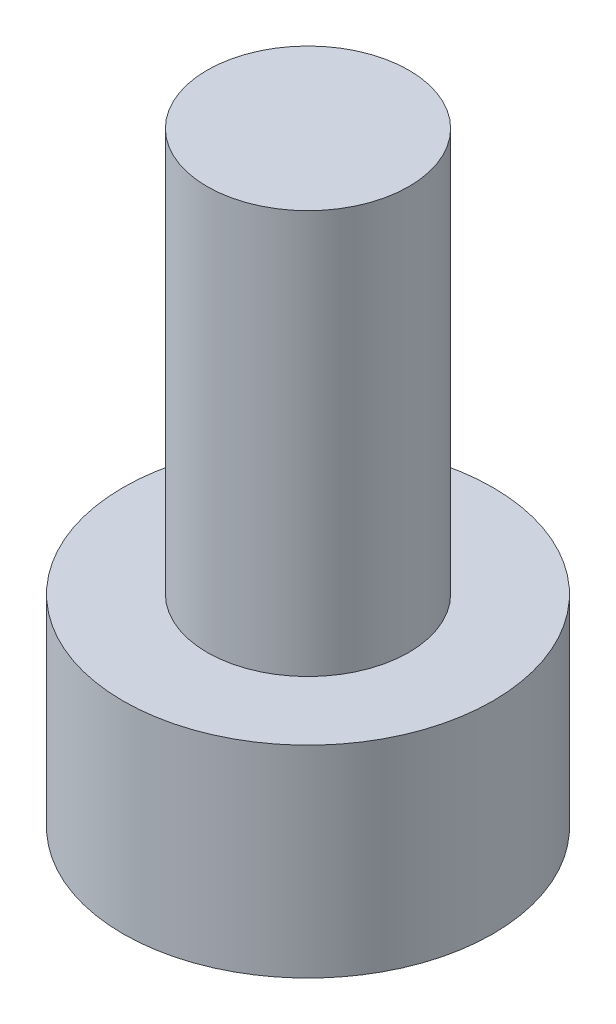
from build123d import *

# Parameters (mm, degrees)
SKETCH_1_R          = 2.75
EXTRUDE_1_DEPTH     = 3
SKETCH_2_R          = 1.5
EXTRUDE_2_DEPTH     = 6
CUT_EXTRUDE_1_DEPTH = 1.3


with BuildPart() as part:
    # 草图1 → 凸台-拉伸1 (new body)
    with BuildSketch(Plane(origin=(0, 0, 0), x_dir=(1, 0, 0), z_dir=(0, 1, 0))):
        Circle(SKETCH_1_R)
    extrude(amount=EXTRUDE_1_DEPTH)

    # 草图2 → 凸台-拉伸2 (add)
    with BuildSketch(Plane(origin=(0, 3, 0), x_dir=(1, 0, 0), z_dir=(0, 1, 0))):
        Circle(SKETCH_2_R)
    extrude(amount=EXTRUDE_2_DEPTH)

    # 草图3 → 切除-拉伸1 (cut)
    with BuildSketch(Plane.XZ):
        Polygon((0.743601936, 1.290680503), (-0.745961136, 1.289318418), (-1.489563072, -0.001362085), (-0.743601936, -1.290680503), (0.745961136, -1.289318418), (1.489563072, 0.001362085), align=None)
    extrude(amount=-CUT_EXTRUDE_1_DEPTH, mode=Mode.SUBTRACT)


solid = part.part
